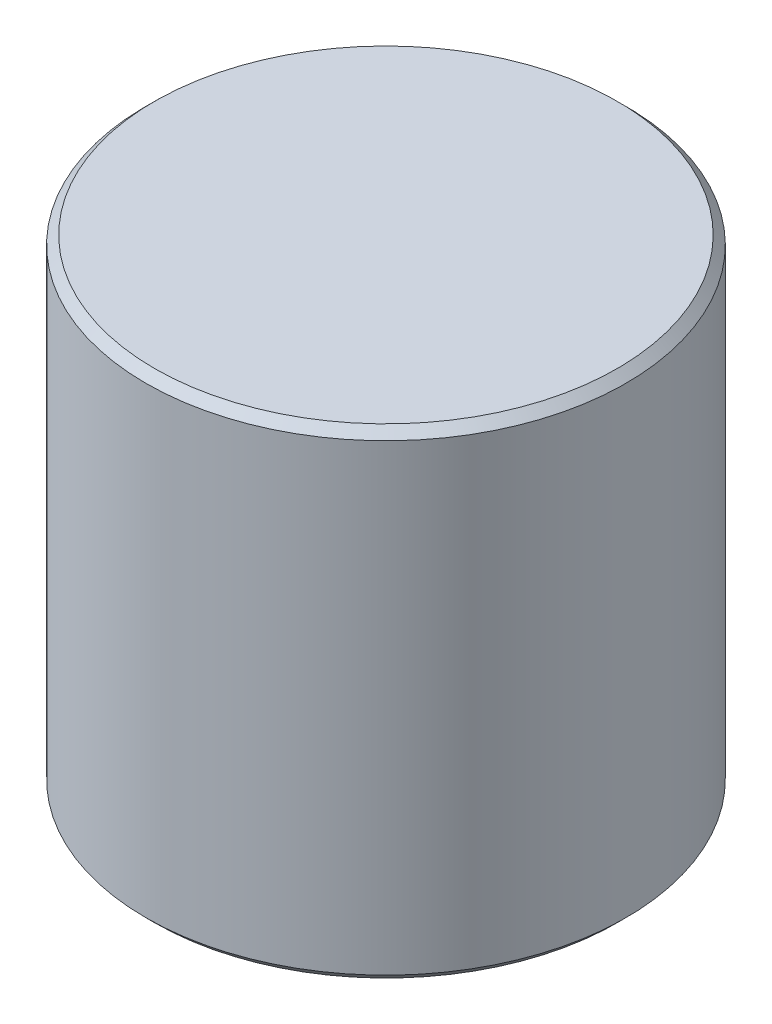
from build123d import *

# Parameters (mm, degrees)
SKETCH1_R           = 17.78
BOSS_EXTRUDE1_DEPTH = 35.56
SKETCH2_R           = 10.5
CUT_EXTRUDE1_DEPTH  = 1
CHAMFER1_SIZE       = 0.635
CHAMFER2_SIZE       = 0.635


with BuildPart() as part:
    # Sketch1 → Boss-Extrude1 (new body)
    with BuildSketch(Plane.XZ):
        Circle(SKETCH1_R)
    extrude(amount=-BOSS_EXTRUDE1_DEPTH)

    # Sketch2 → Cut-Extrude1 (cut)
    with BuildSketch(Plane.XZ):
        Circle(SKETCH2_R)
    extrude(amount=-CUT_EXTRUDE1_DEPTH, mode=Mode.SUBTRACT)

    # Chamfer1
    chamfer1_edges = [part.edges().sort_by_distance(p)[0] for p in [
        (-17.78, 0, 0),
    ]]
    chamfer(chamfer1_edges, length=CHAMFER1_SIZE)

    # Chamfer2
    chamfer2_edges = [part.edges().sort_by_distance(p)[0] for p in [
        (-17.78, 35.56, 0),
    ]]
    chamfer(chamfer2_edges, length=CHAMFER2_SIZE)


solid = part.part
